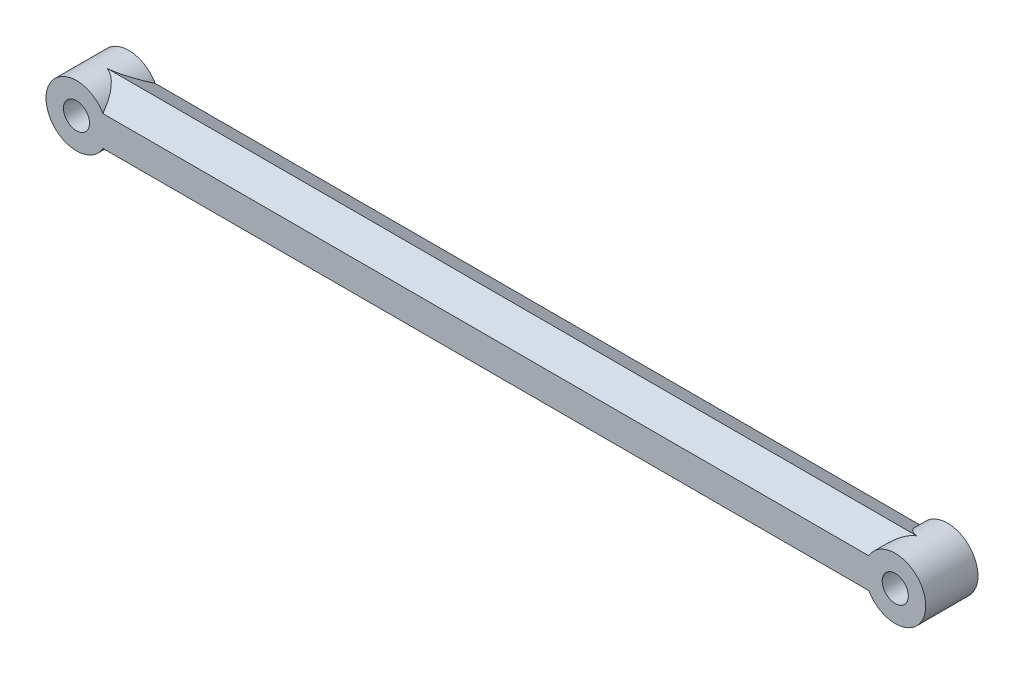
from build123d import *

# Parameters (mm, degrees)
SKETCH1_R                            = 3.5
SKETCH1_R_2                          = 1.5
BOSS_EXTRUDE1_DEPTH                  = 3
BOSS_EXTRUDE1_2_DEPTH                = 3
BOSS_EXTRUDE2_REACH                  = 52.71
BOSS_EXTRUDE2_END_RADIUS             = 3.5
BOSS_EXTRUDE2_DIRECTION_2_REACH      = 52.71
BOSS_EXTRUDE2_DIRECTION_2_END_RADIUS = 3.5


with BuildPart() as part:
    # Sketch1 → Boss-Extrude1 (new, symmetric)
    with BuildSketch(Plane.XY):
        with Locations((-47, 0)):
            Circle(SKETCH1_R)
        with Locations((-47, 0)):
            Circle(SKETCH1_R_2, mode=Mode.SUBTRACT)
    extrude(amount=BOSS_EXTRUDE1_DEPTH, both=True)



with BuildPart() as body_2:
    # Sketch1 → Boss-Extrude1 2 (new, symmetric)
    with BuildSketch(Plane.XY):
        with Locations((47, 0)):
            Circle(SKETCH1_R)
        with Locations((47, 0)):
            Circle(SKETCH1_R_2, mode=Mode.SUBTRACT)
    extrude(amount=BOSS_EXTRUDE1_2_DEPTH, both=True)


with BuildPart() as part_1:
    add(part.part)

    add(body_2.part)  # Boss-Extrude2 merges body 2
    # Boss-Extrude2: up to this cylinder (the profile starts outside it)
    boss_extrude2_end = Plane(origin=(-47, 0, 0), z_dir=(0, 0, -1)) * Cylinder(BOSS_EXTRUDE2_END_RADIUS, 113.42, mode=Mode.PRIVATE)
    # Sketch2 → Boss-Extrude2 (add, up to the surface)
    with BuildSketch(Plane(origin=(0, 0, 0), x_dir=(0, 0, -1), z_dir=(1, 0, 0)), mode=Mode.PRIVATE) as boss_extrude2_sk1:
        Polygon((-3, 1.732050808), (-3, -1.732050808), (0, -3.464101615), (3, -1.732050808), (3, 1.732050808), (0, 3.464101615), align=None)
    boss_extrude2_tool1 = extrude(boss_extrude2_sk1.sketch, amount=-BOSS_EXTRUDE2_REACH, mode=Mode.PRIVATE) - boss_extrude2_end
    add(boss_extrude2_tool1.solids().sort_by_distance((0, 0, 0))[0])

    # Boss-Extrude2 direction 2: up to this cylinder (the profile starts outside it)
    boss_extrude2_direction_2_end = Plane(origin=(47, 0, 0), z_dir=(0, 0, -1)) * Cylinder(BOSS_EXTRUDE2_DIRECTION_2_END_RADIUS, 113.42, mode=Mode.PRIVATE)
    # Sketch2 → Boss-Extrude2 direction 2 (add, up to the surface)
    with BuildSketch(Plane(origin=(0, 0, 0), x_dir=(0, 0, -1), z_dir=(1, 0, 0)), mode=Mode.PRIVATE) as boss_extrude2_direction_2_sk1:
        Polygon((-3, 1.732050808), (-3, -1.732050808), (0, -3.464101615), (3, -1.732050808), (3, 1.732050808), (0, 3.464101615), align=None)
    boss_extrude2_direction_2_tool1 = extrude(boss_extrude2_direction_2_sk1.sketch, amount=BOSS_EXTRUDE2_DIRECTION_2_REACH, mode=Mode.PRIVATE) - boss_extrude2_direction_2_end
    add(boss_extrude2_direction_2_tool1.solids().sort_by_distance((0, 0, 0))[0])


solid = part_1.part
